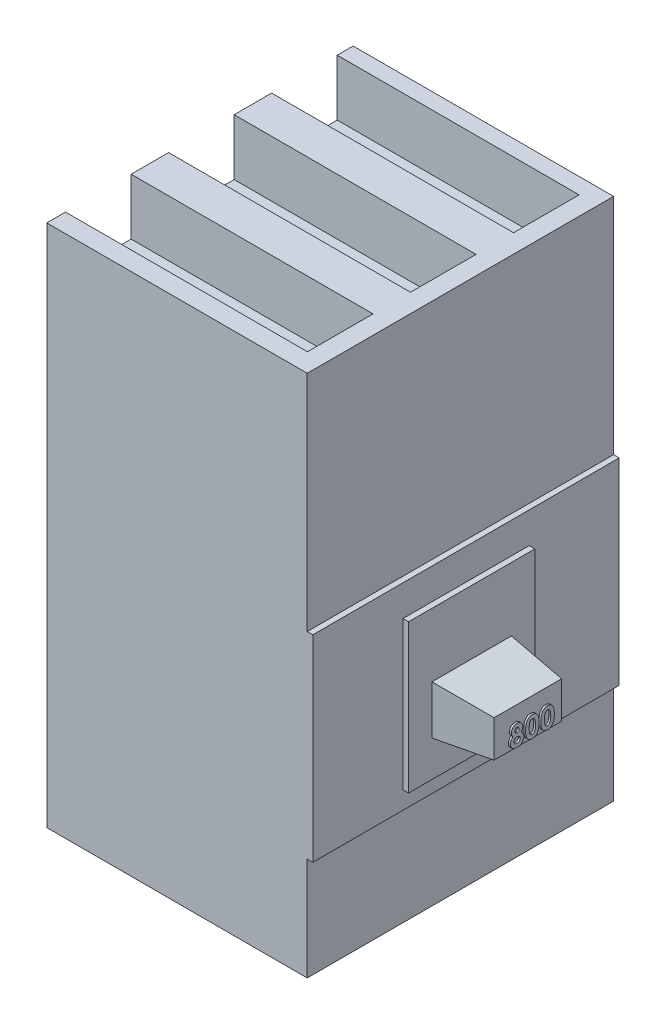
from build123d import *

# Parameters (mm, degrees)
CROQUIS1_W              = 139
CROQUIS1_H              = 279.5
SALIENTE_EXTRUIR1_DEPTH = 163.5
CROQUIS2_W              = 163.5
CROQUIS2_H              = 105.145046647
SALIENTE_EXTRUIR2_DEPTH = 3
CROQUIS3_W              = 67.340086054
CROQUIS3_H              = 79.154136239
SALIENTE_EXTRUIR3_DEPTH = 3
CROQUIS4_W              = 42.38072231
CROQUIS4_H              = 25.920456355
SALIENTE_EXTRUIR4_DEPTH = 30
SALIENTE_EXTRUIR4_TAPER = 6
CROQUIS6_W              = 129.108070307
CROQUIS6_H              = 35
CORTAR_EXTRUIR1_DEPTH   = 30
CROQUIS7_R              = 8
CORTAR_EXTRUIR2_DEPTH   = 30
SALIENTE_EXTRUIR5_DEPTH = 1


with BuildPart() as part:
    # Croquis1 → Saliente-Extruir1 (new body)
    with BuildSketch(Plane.XY):
        Rectangle(CROQUIS1_W, CROQUIS1_H)
    extrude(amount=SALIENTE_EXTRUIR1_DEPTH)

    # Croquis2 → Saliente-Extruir2 (add)
    with BuildSketch(Plane(origin=(69.5, 0, 0), x_dir=(0, 0, -1), z_dir=(1, 0, 0))):
        with Locations((-81.75, -32.193286755)):
            Rectangle(CROQUIS2_W, CROQUIS2_H)
    extrude(amount=SALIENTE_EXTRUIR2_DEPTH)

    # Croquis3 → Saliente-Extruir3 (add)
    with BuildSketch(Plane(origin=(72.5, 0, 0), x_dir=(0, 0, -1), z_dir=(1, 0, 0))):
        with Locations((-81.75, -35.73750181)):
            Rectangle(CROQUIS3_W, CROQUIS3_H)
    extrude(amount=SALIENTE_EXTRUIR3_DEPTH)

    # Croquis4 → Saliente-Extruir4 (add)
    with BuildSketch(Plane(origin=(75.5, 0, 0), x_dir=(0, 0, -1), z_dir=(1, 0, 0))):
        with Locations((-81.75, -43.114642771)):
            Rectangle(CROQUIS4_W, CROQUIS4_H)
    extrude(amount=SALIENTE_EXTRUIR4_DEPTH, taper=SALIENTE_EXTRUIR4_TAPER)

    # Croquis6 → Cortar-Extruir1 (cut)
    with BuildSketch(Plane(origin=(0, 139.75, 0), x_dir=(1, 0, 0), z_dir=(0, 1, 0))):
        with Locations((-4.945964846, -136)):
            Rectangle(CROQUIS6_W, CROQUIS6_H)
        with Locations((-4.945964846, -81)):
            Rectangle(CROQUIS6_W, CROQUIS6_H)
        with Locations((-4.945964846, -26)):
            Rectangle(CROQUIS6_W, CROQUIS6_H)
    extrude(amount=-CORTAR_EXTRUIR1_DEPTH, mode=Mode.SUBTRACT)

    # Croquis7 → Cortar-Extruir2 (cut)
    with BuildSketch(Plane(origin=(0, 109.75, 0), x_dir=(1, 0, 0), z_dir=(0, 1, 0))):
        with Locations((-40.621147944, -136)):
            Circle(CROQUIS7_R)
        with Locations((-40.621147944, -81)):
            Circle(CROQUIS7_R)
        with Locations((-40.621147944, -26)):
            Circle(CROQUIS7_R)
    extrude(amount=-CORTAR_EXTRUIR2_DEPTH, mode=Mode.SUBTRACT)

    # Croquis8 → Saliente-Extruir5 (add)
    with BuildSketch(Plane(origin=(105.5, 0, 0), x_dir=(0, 0, -1), z_dir=(1, 0, 0))):
        with BuildLine():
            add(Edge.make_bspline(
                [(-86.364850298, -46.19834654), (-86.253870718, -46.277644448), (-86.034196652, -46.434607503), (-85.744087567, -46.715812686), (-85.494202504, -47.029500329), (-85.287165527, -47.373746334), (-85.121293748, -47.740089046), (-85.002554719, -48.124612699), (-84.927133052, -48.523925699), (-84.918894755, -48.795789127), (-84.914730106, -48.933222341)],
                knots=[0, 0, 0, 0, 0.000408748, 0.00080908, 0.001207392, 0.001608795, 0.00201112, 0.002410772, 0.002813723, 0.003225675, 0.003225675, 0.003225675, 0.003225675], degree=3))
            add(Edge.make_bspline(
                [(-84.914730106, -48.933222341), (-84.919754438, -49.082038321), (-84.929719555, -49.377195719), (-85.017824509, -49.810043996), (-85.159273477, -50.225886357), (-85.352591097, -50.620132953), (-85.594975836, -50.980532109), (-85.877497793, -51.29958807), (-86.200513108, -51.568968137), (-86.501249516, -51.751740775), (-86.760103848, -51.873153183), (-86.968997023, -51.950854687), (-87.189574484, -52.019259988), (-87.423410242, -52.073911285), (-87.670461775, -52.116575592), (-87.930376513, -52.14475102), (-88.20332555, -52.16523284), (-88.389465253, -52.167347639), (-88.484909059, -52.16843201)],
                knots=[0, 0, 0, 0, 0.000446065, 0.000884712, 0.001319153, 0.001760986, 0.002197872, 0.002618307, 0.003035248, 0.003454838, 0.003670136, 0.003892216, 0.004122904, 0.004362536, 0.004612091, 0.004874542, 0.00514658, 0.005432858, 0.005432858, 0.005432858, 0.005432858], degree=3))
            add(Edge.make_bspline(
                [(-88.484909059, -52.16843201), (-88.58669041, -52.16705139), (-88.785449319, -52.164355311), (-89.075593053, -52.148053391), (-89.349284309, -52.117998974), (-89.6070972, -52.07843466), (-89.848783685, -52.026079607), (-90.07435092, -51.959696266), (-90.284343563, -51.884111447), (-90.541385589, -51.769027073), (-90.835138012, -51.589298179), (-91.152631258, -51.326090396), (-91.431309099, -51.012601702), (-91.673593089, -50.657631678), (-91.864570462, -50.263364101), (-92.006586928, -49.842173746), (-92.090690762, -49.395201985), (-92.100815922, -49.089048304), (-92.105969422, -48.933222341)],
                knots=[0, 0, 0, 0, 0.000305355, 0.000596298, 0.000871391, 0.001131061, 0.001378491, 0.001612631, 0.001835963, 0.002047565, 0.002456605, 0.002864588, 0.003280449, 0.003710879, 0.004149874, 0.004590342, 0.005041082, 0.005508309, 0.005508309, 0.005508309, 0.005508309], degree=3))
            add(Edge.make_bspline(
                [(-92.105969422, -48.933222341), (-92.101259987, -48.797289823), (-92.092005377, -48.530165966), (-92.025713351, -48.138745034), (-91.912042671, -47.767631676), (-91.756068806, -47.414242352), (-91.554943155, -47.078537742), (-91.307476379, -46.762987971), (-91.016806105, -46.46474634), (-90.796385404, -46.288619419), (-90.683409994, -46.19834654)],
                knots=[0, 0, 0, 0, 0.000407719, 0.000801217, 0.00118684, 0.001569357, 0.001957304, 0.002357636, 0.002769915, 0.003203414, 0.003203414, 0.003203414, 0.003203414], degree=3))
            add(Edge.make_bspline(
                [(-90.683409994, -46.19834654), (-90.753448756, -46.117567074), (-90.891333985, -45.958536636), (-91.069758829, -45.702589818), (-91.220074246, -45.438708382), (-91.347699192, -45.169033862), (-91.442042805, -44.888923137), (-91.513388326, -44.602780121), (-91.553741284, -44.307689672), (-91.560048573, -44.10878994), (-91.563234379, -44.00832584)],
                knots=[0, 0, 0, 0, 0.000320578, 0.000631121, 0.000934052, 0.001230936, 0.001524593, 0.001819228, 0.002114556, 0.00241597, 0.00241597, 0.00241597, 0.00241597], degree=3))
            add(Edge.make_bspline(
                [(-91.563234379, -44.00832584), (-91.559010484, -43.872327066), (-91.550676902, -43.604006724), (-91.476866846, -43.211659031), (-91.35432423, -42.838850526), (-91.18761543, -42.486672734), (-90.975921164, -42.162800993), (-90.724382544, -41.872360441), (-90.429463434, -41.625989803), (-90.102131081, -41.414592921), (-89.740744741, -41.246449802), (-89.348733211, -41.12879584), (-88.930830089, -41.054314679), (-88.642823732, -41.046407918), (-88.495509353, -41.042363634)],
                knots=[0, 0, 0, 0, 0.000407719, 0.000804413, 0.001192593, 0.001582343, 0.001969851, 0.00234998, 0.002730559, 0.003118692, 0.003516116, 0.003921846, 0.004343583, 0.004785172, 0.004785172, 0.004785172, 0.004785172], degree=3))
            add(Edge.make_bspline(
                [(-88.495509353, -41.042363634), (-88.350316686, -41.046414537), (-88.067221386, -41.05431295), (-87.656662352, -41.128300597), (-87.273122268, -41.248575323), (-86.91977273, -41.420268694), (-86.59582563, -41.63207302), (-86.305918893, -41.887022053), (-86.055169609, -42.184696498), (-85.841718146, -42.516946706), (-85.671630129, -42.874898165), (-85.54588466, -43.250284581), (-85.473151995, -43.640155381), (-85.462715007, -43.904859259), (-85.457465149, -44.038006662)],
                knots=[0, 0, 0, 0, 0.000435237, 0.000848622, 0.001246888, 0.001637554, 0.002023289, 0.002404817, 0.002791372, 0.003187147, 0.003586378, 0.003977234, 0.004371844, 0.004771226, 0.004771226, 0.004771226, 0.004771226], degree=3))
            add(Edge.make_bspline(
                [(-85.457465149, -44.038006662), (-85.459994132, -44.132108047), (-85.464957072, -44.316774979), (-85.501652049, -44.588841486), (-85.563441887, -44.849889665), (-85.649590912, -45.106227977), (-85.769367465, -45.364822564), (-85.931452991, -45.630628566), (-86.128608748, -45.914690275), (-86.283445015, -46.100602859), (-86.364850298, -46.19834654)],
                knots=[0, 0, 0, 0, 0.000282255, 0.000553904, 0.000821821, 0.00108597, 0.0013639, 0.001674769, 0.002018833, 0.002400261, 0.002400261, 0.002400261, 0.002400261], degree=3))
        make_face()
        with BuildLine():
            add(Edge.make_bspline(
                [(-88.542150646, -42.941936283), (-88.620360018, -42.945706699), (-88.772494528, -42.95304099), (-88.989572659, -43.019241092), (-89.184732981, -43.127516065), (-89.353520575, -43.276523738), (-89.491935201, -43.457322225), (-89.593662346, -43.665187033), (-89.653987746, -43.897552876), (-89.660374362, -44.060259843), (-89.66366173, -44.144009601)],
                knots=[0, 0, 0, 0, 0.000234168, 0.000455509, 0.000673782, 0.000899148, 0.001126004, 0.001352612, 0.001589148, 0.001840042, 0.001840042, 0.001840042, 0.001840042], degree=3))
            add(Edge.make_bspline(
                [(-89.66366173, -44.144009601), (-89.659600826, -44.228474598), (-89.65167152, -44.393400647), (-89.589316432, -44.630230992), (-89.483030462, -44.844866636), (-89.337100545, -45.032824543), (-89.159772063, -45.186343126), (-88.961218524, -45.303592074), (-88.739237933, -45.370526459), (-88.584982724, -45.379603), (-88.506109647, -45.384243976)],
                knots=[0, 0, 0, 0, 0.000253176, 0.000494351, 0.000728538, 0.000967287, 0.001203224, 0.00142832, 0.001654333, 0.001890812, 0.001890812, 0.001890812, 0.001890812], degree=3))
            add(Edge.make_bspline(
                [(-88.506109647, -45.384243976), (-88.425745432, -45.380648015), (-88.269180865, -45.373642409), (-88.046646017, -45.304971264), (-87.846170558, -45.195145763), (-87.674492948, -45.039876803), (-87.532291147, -44.851850825), (-87.42872886, -44.633464236), (-87.369122148, -44.388820235), (-87.361164442, -44.217836537), (-87.357037798, -44.129169189)],
                knots=[0, 0, 0, 0, 0.000240503, 0.000468545, 0.000691554, 0.000921314, 0.001157489, 0.001394566, 0.001641378, 0.001907232, 0.001907232, 0.001907232, 0.001907232], degree=3))
            add(Edge.make_bspline(
                [(-87.357037798, -44.129169189), (-87.361268829, -44.045474796), (-87.369451493, -43.883612781), (-87.42812433, -43.651231864), (-87.535879928, -43.446611332), (-87.677456883, -43.266935564), (-87.854956442, -43.122038235), (-88.061020429, -43.015479864), (-88.294131475, -42.953674977), (-88.457687297, -42.945933915), (-88.542150646, -42.941936283)],
                knots=[0, 0, 0, 0, 0.000251064, 0.000485548, 0.000712167, 0.000939962, 0.001167441, 0.00139406, 0.001631137, 0.001884313, 0.001884313, 0.001884313, 0.001884313], degree=3))
        make_face(mode=Mode.SUBTRACT)
        with BuildLine():
            add(Edge.make_bspline(
                [(-88.480668941, -47.283816625), (-88.540102145, -47.284803602), (-88.657244246, -47.286748921), (-88.82945276, -47.309181368), (-88.994704527, -47.342611261), (-89.152794527, -47.388726857), (-89.302924097, -47.451594017), (-89.446365838, -47.527381542), (-89.582624367, -47.616855545), (-89.709678589, -47.718391628), (-89.824505917, -47.829837153), (-89.928012307, -47.946071221), (-90.012614168, -48.0700988), (-90.083067347, -48.197797174), (-90.139676876, -48.330178283), (-90.177100052, -48.469422169), (-90.20119534, -48.613674496), (-90.204652761, -48.711933333), (-90.206396773, -48.761497581)],
                knots=[0, 0, 0, 0, 0.000178198, 0.000351227, 0.000520035, 0.000683706, 0.000844341, 0.001007462, 0.001169753, 0.001332653, 0.001494585, 0.001649349, 0.001798719, 0.001943893, 0.002086427, 0.002229417, 0.002375455, 0.002524101, 0.002524101, 0.002524101, 0.002524101], degree=3))
            add(Edge.make_bspline(
                [(-90.206396773, -48.761497581), (-90.205565546, -48.813188199), (-90.203916911, -48.915710142), (-90.179016587, -49.065349199), (-90.14316452, -49.209665793), (-90.092809145, -49.347309034), (-90.025468399, -49.478198786), (-89.945062326, -49.60360758), (-89.848787199, -49.722656029), (-89.739253485, -49.834705838), (-89.616630979, -49.935794766), (-89.484470791, -50.024855874), (-89.344518455, -50.103376704), (-89.1925727, -50.159930517), (-89.034260685, -50.211693534), (-88.865341181, -50.243096911), (-88.687659166, -50.266204387), (-88.566262047, -50.267959202), (-88.503989588, -50.26885936)],
                knots=[0, 0, 0, 0, 0.000154895, 0.000307215, 0.00045376, 0.000600657, 0.000745722, 0.000894505, 0.00104681, 0.001204223, 0.001363834, 0.001522598, 0.001681984, 0.00184379, 0.002008078, 0.002181041, 0.002358279, 0.002544952, 0.002544952, 0.002544952, 0.002544952], degree=3))
            add(Edge.make_bspline(
                [(-88.503989588, -50.26885936), (-88.441041395, -50.267718349), (-88.318375303, -50.265494881), (-88.139062144, -50.245843631), (-87.969463719, -50.214662814), (-87.809782607, -50.170066982), (-87.659414967, -50.112937945), (-87.520377855, -50.040223986), (-87.389496822, -49.957818835), (-87.270977743, -49.861544975), (-87.162761087, -49.756626563), (-87.069517245, -49.641644905), (-86.99023304, -49.520297396), (-86.926281688, -49.391272878), (-86.874678691, -49.255180397), (-86.839282273, -49.110662966), (-86.817317522, -48.959344628), (-86.815318467, -48.856270337), (-86.814302756, -48.803898756)],
                knots=[0, 0, 0, 0, 0.000188792, 0.000367897, 0.000540457, 0.000705577, 0.000864638, 0.001022037, 0.001175533, 0.001327838, 0.001479255, 0.001626931, 0.001771001, 0.001913219, 0.002058129, 0.00220673, 0.00235874, 0.002515753, 0.002515753, 0.002515753, 0.002515753], degree=3))
            add(Edge.make_bspline(
                [(-86.814302756, -48.803898756), (-86.816242165, -48.750842492), (-86.820033038, -48.647135881), (-86.840776137, -48.49398868), (-86.879688074, -48.348802738), (-86.930596254, -48.208210831), (-86.998315823, -48.075122271), (-87.082388202, -47.949817944), (-87.178083205, -47.829193912), (-87.289929521, -47.718619918), (-87.412216075, -47.617515986), (-87.542370621, -47.52744348), (-87.679992267, -47.451160374), (-87.825457453, -47.388802726), (-87.979297677, -47.342587266), (-88.140339131, -47.309182542), (-88.308317648, -47.286743901), (-88.422647055, -47.284802089), (-88.480668941, -47.283816625)],
                knots=[0, 0, 0, 0, 0.00015923, 0.00031124, 0.00046242, 0.000609317, 0.000759123, 0.000909064, 0.001061369, 0.001220274, 0.001379885, 0.001536899, 0.001694426, 0.001851153, 0.002010764, 0.00217542, 0.002344241, 0.002518203, 0.002518203, 0.002518203, 0.002518203], degree=3))
        make_face(mode=Mode.SUBTRACT)
        with BuildLine():
            add(Edge.make_bspline(
                [(-80.401125004, -41.042363634), (-80.309177804, -41.043728616), (-80.128385042, -41.046412535), (-79.862111334, -41.07548157), (-79.605616133, -41.119396774), (-79.357895999, -41.18064317), (-79.120734045, -41.261700594), (-78.892404159, -41.35872494), (-78.675624125, -41.476805337), (-78.467629307, -41.610183209), (-78.268499824, -41.761185869), (-78.083021614, -41.933336697), (-77.907807451, -42.122674497), (-77.746650076, -42.332061717), (-77.59598061, -42.559593756), (-77.456294127, -42.805306696), (-77.328659963, -43.070403135), (-77.211647642, -43.355361462), (-77.107014855, -43.664453079), (-77.018882788, -44.001223401), (-76.943294794, -44.365749335), (-76.879493194, -44.758938242), (-76.831269496, -45.181312763), (-76.798765752, -45.632592293), (-76.776460145, -46.111906833), (-76.774639717, -46.440712669), (-76.773704465, -46.609637939)],
                knots=[0, 0, 0, 0, 0.000275738, 0.000542175, 0.000802537, 0.001056032, 0.001306773, 0.001553694, 0.001799374, 0.002046368, 0.002294424, 0.00254799, 0.002804552, 0.003067474, 0.003339718, 0.003622664, 0.00391471, 0.004221796, 0.004546283, 0.004892885, 0.005265437, 0.005662771, 0.006087471, 0.006540316, 0.007019918, 0.007526652, 0.007526652, 0.007526652, 0.007526652], degree=3))
            add(Edge.make_bspline(
                [(-76.773704465, -46.609637939), (-76.77471522, -46.780676654), (-76.776679098, -47.113001809), (-76.797838502, -47.596700403), (-76.834275995, -48.051256494), (-76.881239265, -48.476623055), (-76.9455661, -48.872575456), (-77.020901765, -49.240138948), (-77.11042497, -49.579180299), (-77.218504327, -49.888935576), (-77.33480837, -50.174394352), (-77.462791668, -50.438973916), (-77.600223492, -50.683390897), (-77.74395157, -50.911332656), (-77.901855603, -51.116079587), (-78.066249957, -51.304594155), (-78.244292655, -51.469695599), (-78.428487413, -51.619892506), (-78.625582028, -51.749692776), (-78.833543916, -51.863213952), (-79.056080677, -51.955293108), (-79.289135842, -52.035378641), (-79.536681886, -52.092871412), (-79.794785336, -52.138490036), (-80.066360127, -52.163701686), (-80.251259183, -52.166829357), (-80.346003477, -52.16843201)],
                knots=[0, 0, 0, 0, 0.000513094, 0.000996932, 0.001452054, 0.001880966, 0.002280393, 0.00265502, 0.003006266, 0.003331438, 0.003638525, 0.00393057, 0.004212474, 0.004479467, 0.004738123, 0.004987426, 0.005228898, 0.005465634, 0.005699658, 0.005935862, 0.006175269, 0.006421314, 0.006674304, 0.006936755, 0.007207202, 0.007491416, 0.007491416, 0.007491416, 0.007491416], degree=3))
            add(Edge.make_bspline(
                [(-80.346003477, -52.16843201), (-80.440745213, -52.166798443), (-80.626342882, -52.163598309), (-80.898652038, -52.138677495), (-81.158123306, -52.09268661), (-81.407627837, -52.034937254), (-81.645429119, -51.955470306), (-81.872667402, -51.860636207), (-82.087595419, -51.747823346), (-82.290808273, -51.617720654), (-82.481612138, -51.468528678), (-82.662972103, -51.301843192), (-82.834486991, -51.118086703), (-82.993547635, -50.915200984), (-83.142758988, -50.695894138), (-83.280565011, -50.457661786), (-83.406882886, -50.200850791), (-83.52566386, -49.925103182), (-83.628869492, -49.624482431), (-83.720717712, -49.296304032), (-83.795957357, -48.937832348), (-83.856470115, -48.549182541), (-83.904783466, -48.131177984), (-83.940723046, -47.683616917), (-83.961999981, -47.206290878), (-83.963943264, -46.878200914), (-83.964943781, -46.709280701)],
                knots=[0, 0, 0, 0, 0.000284214, 0.000556772, 0.000819223, 0.001074274, 0.001324342, 0.001570433, 0.00181225, 0.002051601, 0.002293325, 0.002537905, 0.002789915, 0.003046521, 0.003310543, 0.00358508, 0.003871414, 0.004168721, 0.004485186, 0.004824163, 0.005190492, 0.005583304, 0.006003793, 0.006452575, 0.006930059, 0.007436793, 0.007436793, 0.007436793, 0.007436793], degree=3))
            add(Edge.make_bspline(
                [(-83.964943781, -46.709280701), (-83.963131437, -46.474579363), (-83.959634496, -46.021720108), (-83.915318692, -45.367470154), (-83.850274331, -44.762729403), (-83.754739572, -44.208509439), (-83.636612164, -43.702757593), (-83.485343868, -43.248805491), (-83.313135916, -42.840371691), (-83.166392617, -42.598413048), (-83.095719689, -42.481883532)],
                knots=[0, 0, 0, 0, 0.000703974, 0.001358328, 0.001966341, 0.002527841, 0.003044622, 0.003522633, 0.003962202, 0.004370581, 0.004370581, 0.004370581, 0.004370581], degree=3))
            add(Edge.make_bspline(
                [(-83.095719689, -42.481883532), (-83.013544575, -42.367404972), (-82.852876035, -42.143576828), (-82.571942601, -41.849732315), (-82.270116204, -41.598422098), (-81.941197501, -41.395333553), (-81.590388478, -41.23517791), (-81.214677261, -41.122061783), (-80.81545129, -41.056155057), (-80.541296156, -41.047029424), (-80.401125004, -41.042363634)],
                knots=[0, 0, 0, 0, 0.000422318, 0.000825714, 0.001215788, 0.001597598, 0.00198185, 0.002369502, 0.002771364, 0.003191783, 0.003191783, 0.003191783, 0.003191783], degree=3))
        make_face()
        with BuildLine():
            add(Edge.make_bspline(
                [(-80.354483712, -42.941936283), (-80.437604743, -42.945876055), (-80.600566089, -42.953600099), (-80.837030765, -43.019166333), (-81.060002191, -43.120436917), (-81.229610599, -43.24230023), (-81.356560806, -43.359120831), (-81.445261826, -43.464839675), (-81.530799979, -43.582814286), (-81.606351584, -43.718368251), (-81.67769202, -43.866630957), (-81.747413131, -44.028275426), (-81.804566133, -44.207271997), (-81.860717443, -44.400572336), (-81.90991123, -44.613520682), (-81.951124838, -44.847857655), (-81.987945575, -45.105107168), (-82.013628478, -45.38543772), (-82.037572651, -45.688556017), (-82.054736968, -46.015137289), (-82.061912938, -46.365093431), (-82.06419396, -46.606103032), (-82.065371132, -46.730481289)],
                knots=[0, 0, 0, 0, 0.000248951, 0.000488077, 0.000730914, 0.000980325, 0.001110825, 0.001247646, 0.001393546, 0.001547378, 0.001712362, 0.001887186, 0.002074904, 0.00227555, 0.002491025, 0.002730141, 0.002989188, 0.003270389, 0.003574453, 0.003901383, 0.004251295, 0.00462445, 0.00462445, 0.00462445, 0.00462445], degree=3))
            add(Edge.make_bspline(
                [(-82.065371132, -46.730481289), (-82.06343365, -46.891619333), (-82.059718386, -47.20061348), (-82.04025957, -47.644957823), (-82.001255987, -48.049346955), (-81.952743405, -48.416521571), (-81.884605503, -48.744100444), (-81.806208436, -49.035182776), (-81.709395029, -49.286057972), (-81.597508483, -49.500354253), (-81.473589091, -49.682655654), (-81.339069141, -49.837612666), (-81.198528553, -49.971798128), (-81.047580601, -50.080795325), (-80.886585399, -50.164325752), (-80.716886961, -50.224408157), (-80.538377448, -50.261187099), (-80.416135974, -50.266287156), (-80.354483712, -50.26885936)],
                knots=[0, 0, 0, 0, 0.000483448, 0.000927047, 0.001333772, 0.001701955, 0.002037494, 0.002336866, 0.002605369, 0.002842447, 0.003060607, 0.003265036, 0.003457015, 0.003642348, 0.003821565, 0.003999258, 0.004180953, 0.004365837, 0.004365837, 0.004365837, 0.004365837], degree=3))
            add(Edge.make_bspline(
                [(-80.354483712, -50.26885936), (-80.29494716, -50.267099267), (-80.178381994, -50.263653223), (-80.008403877, -50.228280047), (-79.847660492, -50.170770945), (-79.696637172, -50.089420284), (-79.554793729, -49.985970471), (-79.422823406, -49.859966904), (-79.301721496, -49.710153621), (-79.231166974, -49.598970008), (-79.19481157, -49.541679205)],
                knots=[0, 0, 0, 0, 0.0001784, 0.000349285, 0.000518279, 0.000689007, 0.000862022, 0.00104347, 0.001234851, 0.0014383, 0.0014383, 0.0014383, 0.0014383], degree=3))
            add(Edge.make_bspline(
                [(-79.19481157, -49.541679205), (-79.152009204, -49.463393154), (-79.062256114, -49.299233655), (-78.958393683, -49.02222062), (-78.870968077, -48.709795701), (-78.795722137, -48.360986601), (-78.744258504, -47.974417574), (-78.699938086, -47.552539889), (-78.678561248, -47.093229139), (-78.675084188, -46.775016995), (-78.673277115, -46.609637939)],
                knots=[0, 0, 0, 0, 0.000267396, 0.000560709, 0.000884828, 0.001240348, 0.001630116, 0.002054133, 0.002512659, 0.003008825, 0.003008825, 0.003008825, 0.003008825], degree=3))
            add(Edge.make_bspline(
                [(-78.673277115, -46.609637939), (-78.673975148, -46.442823314), (-78.675318743, -46.121733636), (-78.699969827, -45.660771632), (-78.734298345, -45.239759344), (-78.784511057, -44.859636723), (-78.849118836, -44.519480997), (-78.928748169, -44.219314401), (-79.022625229, -43.958545366), (-79.133952234, -43.737433914), (-79.257253809, -43.549519511), (-79.388142195, -43.38830353), (-79.527170841, -43.250661392), (-79.674107246, -43.136075127), (-79.832352305, -43.048522626), (-79.998883331, -42.986703318), (-80.174041724, -42.949304709), (-80.293524546, -42.944425577), (-80.354483712, -42.941936283)],
                knots=[0, 0, 0, 0, 0.000500374, 0.000963135, 0.001384451, 0.001767337, 0.002112855, 0.002422449, 0.00269813, 0.002942747, 0.003163253, 0.003371192, 0.003564582, 0.00374904, 0.003928395, 0.004104819, 0.004280285, 0.004463053, 0.004463053, 0.004463053, 0.004463053], degree=3))
        make_face(mode=Mode.SUBTRACT)
        with BuildLine():
            add(Edge.make_bspline(
                [(-72.260099363, -41.042363634), (-72.168152163, -41.043728616), (-71.9873594, -41.046412535), (-71.721085693, -41.07548157), (-71.464590492, -41.119396774), (-71.216870358, -41.18064317), (-70.979708404, -41.261700594), (-70.751378518, -41.35872494), (-70.534598484, -41.476805337), (-70.326603666, -41.610183209), (-70.127474183, -41.761185869), (-69.941995973, -41.933336697), (-69.76678181, -42.122674497), (-69.605624435, -42.332061717), (-69.454954969, -42.559593756), (-69.315268486, -42.805306696), (-69.187634322, -43.070403135), (-69.070622001, -43.355361462), (-68.965989214, -43.664453079), (-68.877857147, -44.001223401), (-68.802269153, -44.365749335), (-68.738467553, -44.758938242), (-68.690243855, -45.181312763), (-68.657740111, -45.632592293), (-68.635434504, -46.111906833), (-68.633614076, -46.440712669), (-68.632678824, -46.609637939)],
                knots=[0, 0, 0, 0, 0.000275738, 0.000542175, 0.000802537, 0.001056032, 0.001306773, 0.001553694, 0.001799374, 0.002046368, 0.002294424, 0.00254799, 0.002804552, 0.003067474, 0.003339718, 0.003622664, 0.00391471, 0.004221796, 0.004546283, 0.004892885, 0.005265437, 0.005662771, 0.006087471, 0.006540316, 0.007019918, 0.007526652, 0.007526652, 0.007526652, 0.007526652], degree=3))
            add(Edge.make_bspline(
                [(-68.632678824, -46.609637939), (-68.633689579, -46.780676654), (-68.635653457, -47.113001809), (-68.656812861, -47.596700403), (-68.693250354, -48.051256494), (-68.740213624, -48.476623055), (-68.804540459, -48.872575456), (-68.879876124, -49.240138948), (-68.969399329, -49.579180299), (-69.077478686, -49.888935576), (-69.193782728, -50.174394352), (-69.321766027, -50.438973916), (-69.459197851, -50.683390897), (-69.602925929, -50.911332656), (-69.760829962, -51.116079587), (-69.925224316, -51.304594155), (-70.103267014, -51.469695599), (-70.287461772, -51.619892506), (-70.484556387, -51.749692776), (-70.692518275, -51.863213952), (-70.915055036, -51.955293108), (-71.148110201, -52.035378641), (-71.395656245, -52.092871412), (-71.653759695, -52.138490036), (-71.925334486, -52.163701686), (-72.110233542, -52.166829357), (-72.204977836, -52.16843201)],
                knots=[0, 0, 0, 0, 0.000513094, 0.000996932, 0.001452054, 0.001880966, 0.002280393, 0.00265502, 0.003006266, 0.003331438, 0.003638525, 0.00393057, 0.004212474, 0.004479467, 0.004738123, 0.004987426, 0.005228898, 0.005465634, 0.005699658, 0.005935862, 0.006175269, 0.006421314, 0.006674304, 0.006936755, 0.007207202, 0.007491416, 0.007491416, 0.007491416, 0.007491416], degree=3))
            add(Edge.make_bspline(
                [(-72.204977836, -52.16843201), (-72.299719572, -52.166798443), (-72.485317241, -52.163598309), (-72.757626397, -52.138677495), (-73.017097665, -52.09268661), (-73.266602196, -52.034937254), (-73.504403478, -51.955470306), (-73.731641761, -51.860636207), (-73.946569778, -51.747823346), (-74.149782632, -51.617720654), (-74.340586497, -51.468528678), (-74.521946462, -51.301843192), (-74.69346135, -51.118086703), (-74.852521994, -50.915200984), (-75.001733347, -50.695894138), (-75.13953937, -50.457661786), (-75.265857245, -50.200850791), (-75.384638219, -49.925103182), (-75.487843851, -49.624482431), (-75.579692071, -49.296304032), (-75.654931716, -48.937832348), (-75.715444474, -48.549182541), (-75.763757825, -48.131177984), (-75.799697405, -47.683616917), (-75.82097434, -47.206290878), (-75.822917623, -46.878200914), (-75.82391814, -46.709280701)],
                knots=[0, 0, 0, 0, 0.000284214, 0.000556772, 0.000819223, 0.001074274, 0.001324342, 0.001570433, 0.00181225, 0.002051601, 0.002293325, 0.002537905, 0.002789915, 0.003046521, 0.003310543, 0.00358508, 0.003871414, 0.004168721, 0.004485186, 0.004824163, 0.005190492, 0.005583304, 0.006003793, 0.006452575, 0.006930059, 0.007436793, 0.007436793, 0.007436793, 0.007436793], degree=3))
            add(Edge.make_bspline(
                [(-75.82391814, -46.709280701), (-75.822105796, -46.474579363), (-75.818608855, -46.021720108), (-75.774293051, -45.367470154), (-75.70924869, -44.762729403), (-75.613713931, -44.208509439), (-75.495586523, -43.702757593), (-75.344318227, -43.248805491), (-75.172110275, -42.840371691), (-75.025366976, -42.598413048), (-74.954694048, -42.481883532)],
                knots=[0, 0, 0, 0, 0.000703974, 0.001358328, 0.001966341, 0.002527841, 0.003044622, 0.003522633, 0.003962202, 0.004370581, 0.004370581, 0.004370581, 0.004370581], degree=3))
            add(Edge.make_bspline(
                [(-74.954694048, -42.481883532), (-74.872518934, -42.367404972), (-74.711850394, -42.143576828), (-74.43091696, -41.849732315), (-74.129090563, -41.598422098), (-73.80017186, -41.395333553), (-73.449362837, -41.23517791), (-73.07365162, -41.122061783), (-72.674425649, -41.056155057), (-72.400270515, -41.047029424), (-72.260099363, -41.042363634)],
                knots=[0, 0, 0, 0, 0.000422318, 0.000825714, 0.001215788, 0.001597598, 0.00198185, 0.002369502, 0.002771364, 0.003191783, 0.003191783, 0.003191783, 0.003191783], degree=3))
        make_face()
        with BuildLine():
            add(Edge.make_bspline(
                [(-72.213458071, -42.941936283), (-72.296579102, -42.945876055), (-72.459540448, -42.953600099), (-72.696005124, -43.019166333), (-72.91897655, -43.120436917), (-73.088584958, -43.24230023), (-73.215535165, -43.359120831), (-73.304236185, -43.464839675), (-73.389774338, -43.582814286), (-73.465325943, -43.718368251), (-73.536666379, -43.866630957), (-73.60638749, -44.028275426), (-73.663540492, -44.207271997), (-73.719691802, -44.400572336), (-73.768885589, -44.613520682), (-73.810099197, -44.847857655), (-73.846919934, -45.105107168), (-73.872602837, -45.38543772), (-73.89654701, -45.688556017), (-73.913711327, -46.015137289), (-73.920887297, -46.365093431), (-73.923168319, -46.606103032), (-73.924345491, -46.730481289)],
                knots=[0, 0, 0, 0, 0.000248951, 0.000488077, 0.000730914, 0.000980325, 0.001110825, 0.001247646, 0.001393546, 0.001547378, 0.001712362, 0.001887186, 0.002074904, 0.00227555, 0.002491025, 0.002730141, 0.002989188, 0.003270389, 0.003574453, 0.003901383, 0.004251295, 0.00462445, 0.00462445, 0.00462445, 0.00462445], degree=3))
            add(Edge.make_bspline(
                [(-73.924345491, -46.730481289), (-73.922408009, -46.891619333), (-73.918692745, -47.20061348), (-73.899233929, -47.644957823), (-73.860230346, -48.049346955), (-73.811717764, -48.416521571), (-73.743579862, -48.744100444), (-73.665182795, -49.035182776), (-73.568369388, -49.286057972), (-73.456482842, -49.500354253), (-73.33256345, -49.682655654), (-73.1980435, -49.837612666), (-73.057502912, -49.971798128), (-72.90655496, -50.080795325), (-72.745559758, -50.164325752), (-72.57586132, -50.224408157), (-72.397351807, -50.261187099), (-72.275110333, -50.266287156), (-72.213458071, -50.26885936)],
                knots=[0, 0, 0, 0, 0.000483448, 0.000927047, 0.001333772, 0.001701955, 0.002037494, 0.002336866, 0.002605369, 0.002842447, 0.003060607, 0.003265036, 0.003457015, 0.003642348, 0.003821565, 0.003999258, 0.004180953, 0.004365837, 0.004365837, 0.004365837, 0.004365837], degree=3))
            add(Edge.make_bspline(
                [(-72.213458071, -50.26885936), (-72.153921519, -50.267099267), (-72.037356353, -50.263653223), (-71.867378236, -50.228280047), (-71.706634851, -50.170770945), (-71.555611531, -50.089420284), (-71.413768088, -49.985970471), (-71.281797765, -49.859966904), (-71.160695855, -49.710153621), (-71.090141333, -49.598970008), (-71.053785929, -49.541679205)],
                knots=[0, 0, 0, 0, 0.0001784, 0.000349285, 0.000518279, 0.000689007, 0.000862022, 0.00104347, 0.001234851, 0.0014383, 0.0014383, 0.0014383, 0.0014383], degree=3))
            add(Edge.make_bspline(
                [(-71.053785929, -49.541679205), (-71.010983563, -49.463393154), (-70.921230473, -49.299233655), (-70.817368042, -49.02222062), (-70.729942436, -48.709795701), (-70.654696496, -48.360986601), (-70.603232863, -47.974417574), (-70.558912445, -47.552539889), (-70.537535606, -47.093229139), (-70.534058547, -46.775016995), (-70.532251474, -46.609637939)],
                knots=[0, 0, 0, 0, 0.000267396, 0.000560709, 0.000884828, 0.001240348, 0.001630116, 0.002054133, 0.002512659, 0.003008825, 0.003008825, 0.003008825, 0.003008825], degree=3))
            add(Edge.make_bspline(
                [(-70.532251474, -46.609637939), (-70.532949507, -46.442823314), (-70.534293102, -46.121733636), (-70.558944186, -45.660771632), (-70.593272704, -45.239759344), (-70.643485415, -44.859636723), (-70.708093195, -44.519480997), (-70.787722528, -44.219314401), (-70.881599588, -43.958545366), (-70.992926593, -43.737433914), (-71.116228168, -43.549519511), (-71.247116554, -43.38830353), (-71.3861452, -43.250661392), (-71.533081605, -43.136075127), (-71.691326664, -43.048522626), (-71.85785769, -42.986703318), (-72.033016083, -42.949304709), (-72.152498905, -42.944425577), (-72.213458071, -42.941936283)],
                knots=[0, 0, 0, 0, 0.000500374, 0.000963135, 0.001384451, 0.001767337, 0.002112855, 0.002422449, 0.00269813, 0.002942747, 0.003163253, 0.003371192, 0.003564582, 0.00374904, 0.003928395, 0.004104819, 0.004280285, 0.004463053, 0.004463053, 0.004463053, 0.004463053], degree=3))
        make_face(mode=Mode.SUBTRACT)
    extrude(amount=SALIENTE_EXTRUIR5_DEPTH)


solid = part.part
